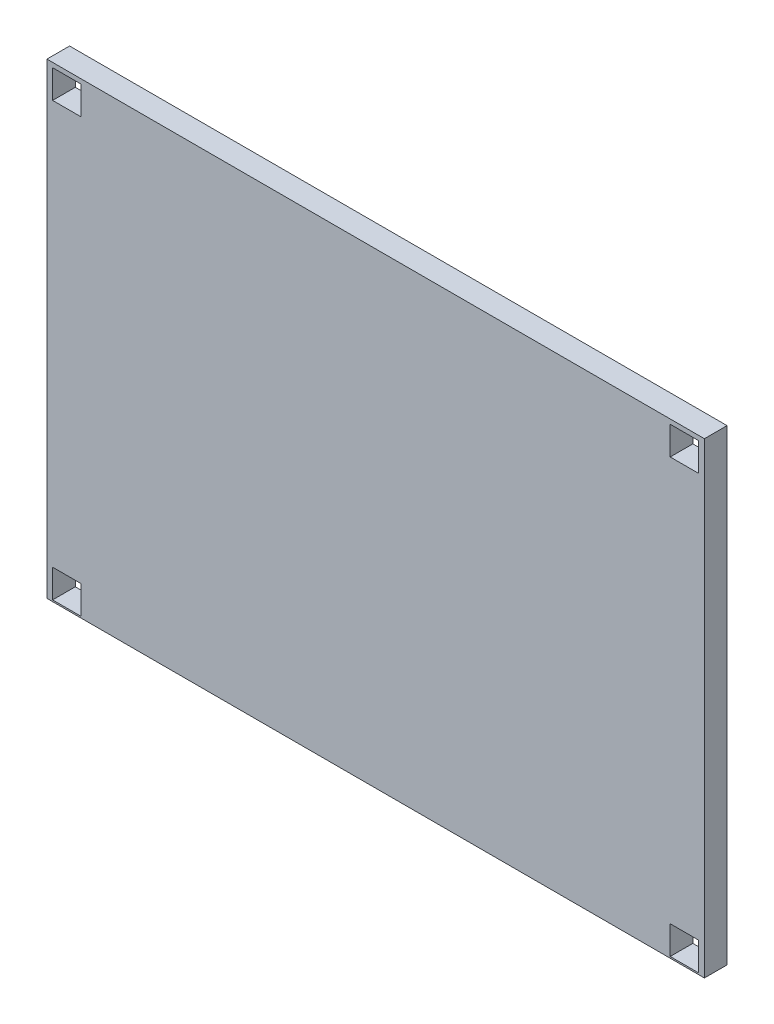
from build123d import *

# Parameters (mm, degrees)
SKETCH2_W           = 147.32
SKETCH2_H           = 104.648
BOSS_EXTRUDE1_DEPTH = 5.08
SKETCH3_R           = 19.05
CUT_EXTRUDE1_DEPTH  = 2.54
SKETCH4_R           = 12.7
CUT_EXTRUDE2_DEPTH  = 3.81
SKETCH5_W           = 6.35
SKETCH5_H           = 6.35
CUT_EXTRUDE3_DEPTH  = 6.35


with BuildPart() as part:
    # Sketch2 → Boss-Extrude1 (new body)
    with BuildSketch(Plane.XY):
        with Locations((117.825395055, 78.266401141)):
            Rectangle(SKETCH2_W, SKETCH2_H)
    extrude(amount=BOSS_EXTRUDE1_DEPTH)

    # Sketch3 → Cut-Extrude1 (cut)
    with BuildSketch(Plane.XY):
        with Locations((69.599550134, 110.562048191)):
            Circle(SKETCH3_R)
        with Locations((69.599550134, 45.622553044)):
            Circle(SKETCH3_R)
        with Locations((92.580819194, 77.831149833)):
            Circle(SKETCH3_R)
        with Locations((115.562088254, 110.562048191)):
            Circle(SKETCH3_R)
        with Locations((115.562088254, 45.622553044)):
            Circle(SKETCH3_R)
        with Locations((140.284362546, 77.831149833)):
            Circle(SKETCH3_R)
        with Locations((165.877139454, 110.562048191)):
            Circle(SKETCH3_R)
        with Locations((165.877139454, 45.622553044)):
            Circle(SKETCH3_R)
    extrude(amount=CUT_EXTRUDE1_DEPTH, mode=Mode.SUBTRACT)

    # Sketch4 → Cut-Extrude2 (cut)
    with BuildSketch(Plane.XY):
        with Locations((69.599550134, 45.622553044)):
            Circle(SKETCH4_R)
        with Locations((115.562088254, 45.622553044)):
            Circle(SKETCH4_R)
        with Locations((165.877139454, 45.622553044)):
            Circle(SKETCH4_R)
        with Locations((92.580819194, 77.831149833)):
            Circle(SKETCH4_R)
        with Locations((140.284362546, 77.831149833)):
            Circle(SKETCH4_R)
        with Locations((69.599550134, 110.562048191)):
            Circle(SKETCH4_R)
        with Locations((115.562088254, 110.562048191)):
            Circle(SKETCH4_R)
        with Locations((165.877139454, 110.562048191)):
            Circle(SKETCH4_R)
    extrude(amount=CUT_EXTRUDE2_DEPTH, mode=Mode.SUBTRACT)

    # Sketch5 → Cut-Extrude3 (cut)
    with BuildSketch(Plane.XY):
        with Locations((48.615350013, 29.461567224)):
            Rectangle(SKETCH5_W, SKETCH5_H)
        with Locations((186.994201874, 29.461567224)):
            Rectangle(SKETCH5_W, SKETCH5_H)
        with Locations((186.994201874, 126.386007845)):
            Rectangle(SKETCH5_W, SKETCH5_H)
        with Locations((48.615350013, 126.386007845)):
            Rectangle(SKETCH5_W, SKETCH5_H)
    extrude(amount=CUT_EXTRUDE3_DEPTH, mode=Mode.SUBTRACT)


solid = part.part
